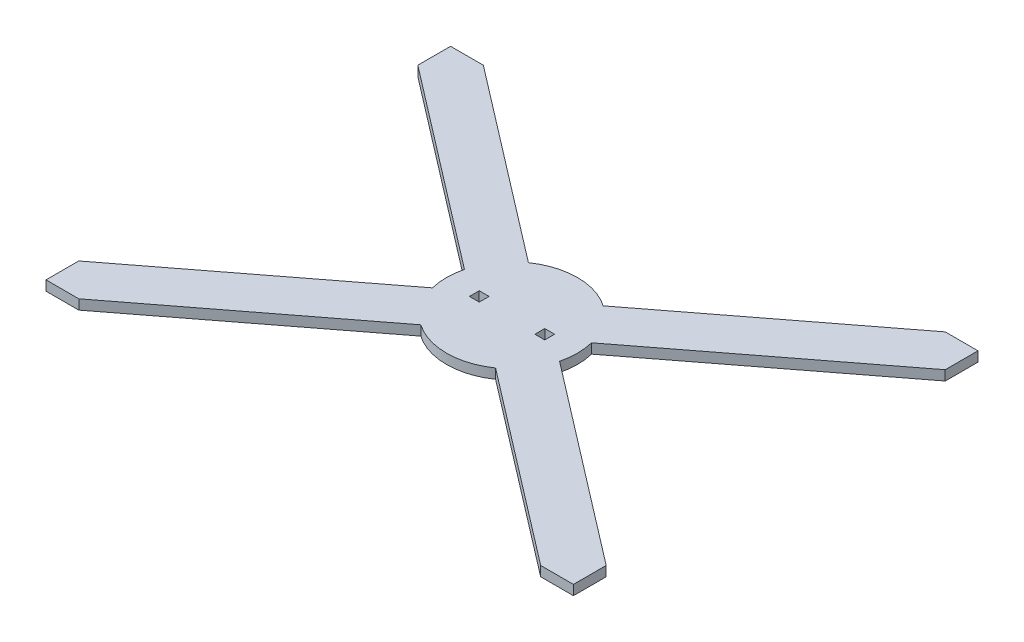
from build123d import *

# Parameters (mm, degrees)
SALIENTE_EXTRUIR1_DEPTH = 6
CROQUIS7_R              = 40
SALIENTE_EXTRUIR5_DEPTH = 6
SALIENTE_EXTRUIR3_DEPTH = 6
CROQUIS6_R              = 1.75
SALIENTE_EXTRUIR4_DEPTH = 6
CROQUIS8_W              = 6
CROQUIS8_H              = 6
CORTAR_EXTRUIR1_DEPTH   = 25
CROQUIS9_R              = 40
CORTAR_EXTRUIR2_DEPTH   = 18


with BuildPart() as part:
    # Croquis1 → Saliente-Extruir1 (new body)
    with BuildSketch(Plane(origin=(0, 0, 0), x_dir=(1, 0, 0), z_dir=(0, 1, 0))):
        with BuildLine():
            Line((-161, 103.5), (-38.791887254, 9.756509788))
            ThreePointArc((-38.791887254, 9.756509788), (-40, 0), (-38.791887254, -9.756509788))
            Line((-38.791887254, -9.756509788), (-161, -103.5))
            Line((-161, -103.5), (-161, -123.5))
            Line((-161, -123.5), (-141, -123.5))
            Line((-141, -123.5), (-22.823766962, -32.84928708))
            ThreePointArc((-22.823766962, -32.84928708), (0, -40), (22.823766962, -32.84928708))
            Line((22.823766962, -32.84928708), (141, -123.5))
            Line((141, -123.5), (161, -123.5))
            Line((161, -123.5), (161, -103.5))
            Line((161, -103.5), (38.791887254, -9.756509788))
            ThreePointArc((38.791887254, -9.756509788), (40, 0), (38.791887254, 9.756509788))
            Line((38.791887254, 9.756509788), (161, 103.5))
            Line((161, 103.5), (161, 123.5))
            Line((161, 123.5), (141, 123.5))
            Line((141, 123.5), (22.823766962, 32.84928708))
            ThreePointArc((22.823766962, 32.84928708), (0, 40), (-22.823766962, 32.84928708))
            Line((-22.823766962, 32.84928708), (-141, 123.5))
            Line((-141, 123.5), (-161, 123.5))
            Line((-161, 123.5), (-161, 103.5))
        make_face()
    extrude(amount=SALIENTE_EXTRUIR1_DEPTH)

    # Croquis7 → Saliente-Extruir5 (add)
    with BuildSketch(Plane(origin=(0, 0, 0), x_dir=(-1, 0, 0), z_dir=(0, -1, 0))):
        Circle(CROQUIS7_R)
    extrude(amount=SALIENTE_EXTRUIR5_DEPTH)

    # Croquis5 → Saliente-Extruir3 (add)
    with BuildSketch(Plane.XZ.offset(6)):
        with BuildLine():
            Line((18.896097481, -21), (-18.896097481, -21))
            ThreePointArc((-18.896097481, -21), (-28.25, 0), (-18.896097481, 21))
            Line((-18.896097481, 21), (-13.25, 21))
            Line((-13.25, 21), (-13.25, -11))
            Line((-13.25, -11), (13.25, -11))
            Line((13.25, -11), (13.25, 21))
            Line((13.25, 21), (18.896097481, 21))
            ThreePointArc((18.896097481, 21), (28.25, 0), (18.896097481, -21))
        make_face()
    extrude(amount=SALIENTE_EXTRUIR3_DEPTH)

    # Croquis6 → Saliente-Extruir4 (add)
    with BuildSketch(Plane.XZ.offset(12)):
        with BuildLine():
            Line((-18.896097481, 21), (-13.25, 21))
            Line((-13.25, 21), (-13.25, 3.5))
            ThreePointArc((-13.25, 3.5), (-13.103553391, 3.146446609), (-12.75, 3))
            Line((-12.75, 3), (12.75, 3))
            ThreePointArc((12.75, 3), (13.103553391, 3.146446609), (13.25, 3.5))
            Line((13.25, 3.5), (13.25, 21))
            Line((13.25, 21), (18.896097481, 21))
            ThreePointArc((18.896097481, 21), (28.25, 0), (18.896097481, -21))
            Line((18.896097481, -21), (-18.896097481, -21))
            ThreePointArc((-18.896097481, -21), (-28.25, 0), (-18.896097481, 21))
        make_face()
        with Locations((-8, -5.75)):
            Circle(CROQUIS6_R, mode=Mode.SUBTRACT)
        with Locations((8, -5.75)):
            Circle(CROQUIS6_R, mode=Mode.SUBTRACT)
    extrude(amount=SALIENTE_EXTRUIR4_DEPTH)

    # Croquis8 → Cortar-Extruir1 (cut, through all)
    with BuildSketch(Plane.XZ.offset(18)):
        with Locations((-20, 0)):
            Rectangle(CROQUIS8_W, CROQUIS8_H)
        with Locations((20, 0)):
            Rectangle(CROQUIS8_W, CROQUIS8_H)
    extrude(amount=-CORTAR_EXTRUIR1_DEPTH, mode=Mode.SUBTRACT)

    # Croquis9 → Cortar-Extruir2 (cut)
    with BuildSketch(Plane(origin=(0, -18, 0), x_dir=(-1, 0, 0), z_dir=(0, -1, 0))):
        Circle(CROQUIS9_R)
    extrude(amount=-CORTAR_EXTRUIR2_DEPTH, mode=Mode.SUBTRACT)


solid = part.part
